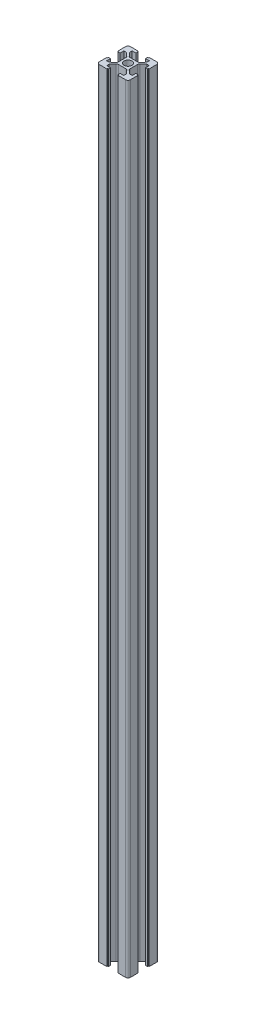
from build123d import *

# Parameters (mm, degrees)
SKETCH1_R           = 2.5
BOSS_EXTRUDE1_DEPTH = 500


with BuildPart() as part:
    # Sketch1 → Boss-Extrude1 (new body)
    with BuildSketch(Plane(origin=(0, 0, 0), x_dir=(1, 0, 0), z_dir=(0, 1, 0))):
        with BuildLine():
            ThreePointArc((-10, -8.5), (-9.560660172, -9.560660172), (-8.5, -10))
            Line((-8.5, -10), (-3.6, -10))
            Line((-3.6, -10), (-3.6, -9.5))
            Line((-3.6, -9.5), (-3.1, -9.5))
            Line((-3.1, -9.5), (-3.1, -8.2))
            Line((-3.1, -8.2), (-5.5, -8.2))
            Line((-5.5, -8.2), (-5.5, -6.6))
            Line((-5.5, -6.6), (-3.54898252, -4.32381294))
            ThreePointArc((-3.54898252, -4.32381294), (-3.036882831, -3.937230652), (-2.410097616, -3.8))
            Line((-2.410097616, -3.8), (2.410097616, -3.8))
            ThreePointArc((2.410097616, -3.8), (3.036882831, -3.937230652), (3.54898252, -4.32381294))
            Line((3.54898252, -4.32381294), (5.5, -6.6))
            Line((5.5, -6.6), (5.5, -8.2))
            Line((5.5, -8.2), (3.1, -8.2))
            Line((3.1, -8.2), (3.1, -9.5))
            Line((3.1, -9.5), (3.6, -9.5))
            Line((3.6, -9.5), (3.6, -10))
            Line((3.6, -10), (8.5, -10))
            ThreePointArc((8.5, -10), (9.560660172, -9.560660172), (10, -8.5))
            Line((10, -8.5), (10, -3.6))
            Line((10, -3.6), (9.5, -3.6))
            Line((9.5, -3.6), (9.5, -3.1))
            Line((9.5, -3.1), (8.2, -3.1))
            Line((8.2, -3.1), (8.2, -5.5))
            Line((8.2, -5.5), (6.6, -5.5))
            Line((6.6, -5.5), (4.32381294, -3.54898252))
            ThreePointArc((4.32381294, -3.54898252), (3.937230652, -3.036882831), (3.8, -2.410097616))
            Line((3.8, -2.410097616), (3.8, 2.410097616))
            ThreePointArc((3.8, 2.410097616), (3.937230652, 3.036882831), (4.32381294, 3.54898252))
            Line((4.32381294, 3.54898252), (6.6, 5.5))
            Line((6.6, 5.5), (8.2, 5.5))
            Line((8.2, 5.5), (8.2, 3.1))
            Line((8.2, 3.1), (9.5, 3.1))
            Line((9.5, 3.1), (9.5, 3.6))
            Line((9.5, 3.6), (10, 3.6))
            Line((10, 3.6), (10, 8.5))
            ThreePointArc((10, 8.5), (9.560660172, 9.560660172), (8.5, 10))
            Line((8.5, 10), (3.6, 10))
            Line((3.6, 10), (3.6, 9.5))
            Line((3.6, 9.5), (3.1, 9.5))
            Line((3.1, 9.5), (3.1, 8.2))
            Line((3.1, 8.2), (5.5, 8.2))
            Line((5.5, 8.2), (5.5, 6.6))
            Line((5.5, 6.6), (3.54898252, 4.32381294))
            ThreePointArc((3.54898252, 4.32381294), (3.036882831, 3.937230652), (2.410097616, 3.8))
            Line((2.410097616, 3.8), (-2.410097616, 3.8))
            ThreePointArc((-2.410097616, 3.8), (-3.036882831, 3.937230652), (-3.54898252, 4.32381294))
            Line((-3.54898252, 4.32381294), (-5.5, 6.6))
            Line((-5.5, 6.6), (-5.5, 8.2))
            Line((-5.5, 8.2), (-3.1, 8.2))
            Line((-3.1, 8.2), (-3.1, 9.5))
            Line((-3.1, 9.5), (-3.6, 9.5))
            Line((-3.6, 9.5), (-3.6, 10))
            Line((-3.6, 10), (-8.5, 10))
            ThreePointArc((-8.5, 10), (-9.560660172, 9.560660172), (-10, 8.5))
            Line((-10, 8.5), (-10, 3.6))
            Line((-10, 3.6), (-9.5, 3.6))
            Line((-9.5, 3.6), (-9.5, 3.1))
            Line((-9.5, 3.1), (-8.2, 3.1))
            Line((-8.2, 3.1), (-8.2, 5.5))
            Line((-8.2, 5.5), (-6.6, 5.5))
            Line((-6.6, 5.5), (-4.32381294, 3.54898252))
            ThreePointArc((-4.32381294, 3.54898252), (-3.937230652, 3.036882831), (-3.8, 2.410097616))
            Line((-3.8, 2.410097616), (-3.8, -2.410097616))
            ThreePointArc((-3.8, -2.410097616), (-3.937230652, -3.036882831), (-4.32381294, -3.54898252))
            Line((-4.32381294, -3.54898252), (-6.6, -5.5))
            Line((-6.6, -5.5), (-8.2, -5.5))
            Line((-8.2, -5.5), (-8.2, -3.1))
            Line((-8.2, -3.1), (-9.5, -3.1))
            Line((-9.5, -3.1), (-9.5, -3.6))
            Line((-9.5, -3.6), (-10, -3.6))
            Line((-10, -3.6), (-10, -8.5))
        make_face()
        Circle(SKETCH1_R, mode=Mode.SUBTRACT)
    extrude(amount=BOSS_EXTRUDE1_DEPTH)


solid = part.part
